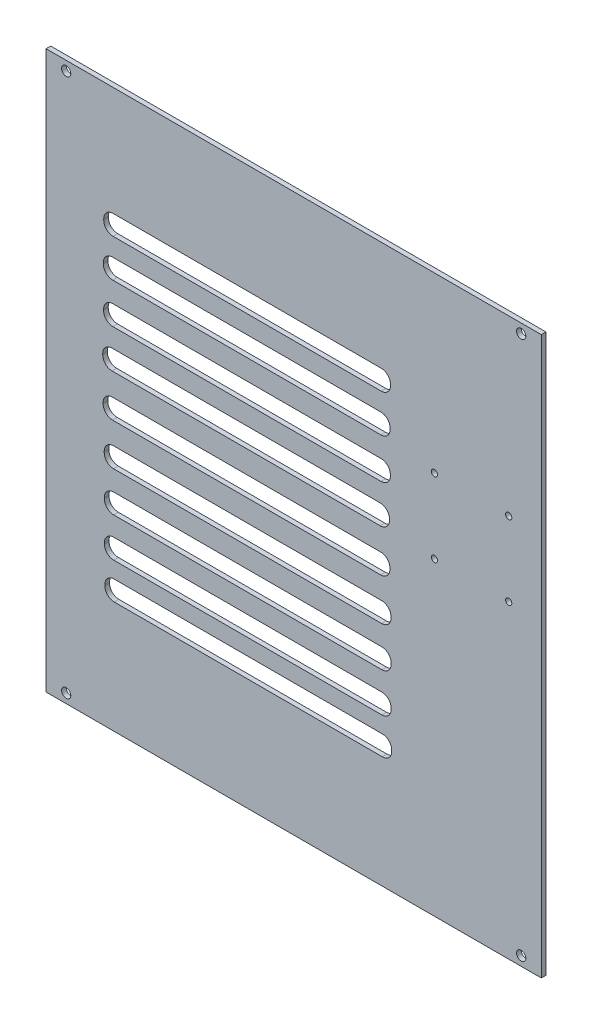
from build123d import *

# Parameters (mm, degrees)
SKETCH_1_W      = 1600
SKETCH_1_H      = 1800
SKETCH_1_R      = 15
SKETCH_1_R_2    = 10
EXTRUDE_1_DEPTH = 3
SCALE_1_SCALE_X = 0.1
SCALE_1_SCALE_Y = 0.1
SCALE_1_SCALE_Z = 0.5


with BuildPart() as part:
    # 草图1 → 凸台-拉伸1 (new body)
    with BuildSketch(Plane.XY):
        with Locations((2560.047324667, 9.612957927)):
            Rectangle(SKETCH_1_W, SKETCH_1_H)
        with Locations((1825.047324667, 879.612957927)):
            Circle(SKETCH_1_R, mode=Mode.SUBTRACT)
        with Locations((1825.047324667, -860.387042073)):
            Circle(SKETCH_1_R, mode=Mode.SUBTRACT)
        with Locations((3295.047324667, -860.387042073)):
            Circle(SKETCH_1_R, mode=Mode.SUBTRACT)
        with Locations((3295.047324667, 879.612957927)):
            Circle(SKETCH_1_R, mode=Mode.SUBTRACT)
        with Locations((3254.707896473, 109.612957927)):
            Circle(SKETCH_1_R_2, mode=Mode.SUBTRACT)
        with Locations((3014.707896473, 109.612957927)):
            Circle(SKETCH_1_R_2, mode=Mode.SUBTRACT)
        with Locations((3254.707896473, 349.612957927)):
            Circle(SKETCH_1_R_2, mode=Mode.SUBTRACT)
        with Locations((3014.707896473, 349.612957927)):
            Circle(SKETCH_1_R_2, mode=Mode.SUBTRACT)
        with BuildLine():
            Line((1975.102126733, 433.943093045), (2841.465354924, 433.943093045))
            ThreePointArc((2841.465354924, 433.943093045), (2862.67855836, 425.15629648), (2871.465354924, 403.943093045))
            Line((2871.465354924, 403.943093045), (2871.465354924, 399.92653687))
            ThreePointArc((2871.465354924, 399.92653687), (2862.67855836, 378.713333435), (2841.465354924, 369.92653687))
            Line((2841.465354924, 369.92653687), (1975.102126733, 369.92653687))
            ThreePointArc((1975.102126733, 369.92653687), (1953.888923298, 378.713333435), (1945.102126733, 399.92653687))
            Line((1945.102126733, 399.92653687), (1945.102126733, 403.943093045))
            ThreePointArc((1945.102126733, 403.943093045), (1953.888923298, 425.15629648), (1975.102126733, 433.943093045))
        make_face(mode=Mode.SUBTRACT)
        with BuildLine():
            Line((1976.452803418, 556.998144036), (2842.816031608, 556.998144036))
            ThreePointArc((2842.816031608, 556.998144036), (2864.029235044, 548.211347472), (2872.816031608, 526.998144036))
            Line((2872.816031608, 526.998144036), (2872.816031608, 522.981587861))
            ThreePointArc((2872.816031608, 522.981587861), (2864.029235044, 501.768384426), (2842.816031608, 492.981587861))
            Line((2842.816031608, 492.981587861), (1976.452803418, 492.981587861))
            ThreePointArc((1976.452803418, 492.981587861), (1955.239599982, 501.768384426), (1946.452803418, 522.981587861))
            Line((1946.452803418, 522.981587861), (1946.452803418, 526.998144036))
            ThreePointArc((1946.452803418, 526.998144036), (1955.239599982, 548.211347472), (1976.452803418, 556.998144036))
        make_face(mode=Mode.SUBTRACT)
        with BuildLine():
            Line((1976.005030783, 304.030402639), (2842.368258974, 304.030402639))
            ThreePointArc((2842.368258974, 304.030402639), (2863.581462409, 295.243606075), (2872.368258974, 274.030402639))
            Line((2872.368258974, 274.030402639), (2872.368258974, 270.013846465))
            ThreePointArc((2872.368258974, 270.013846465), (2863.581462409, 248.800643029), (2842.368258974, 240.013846465))
            Line((2842.368258974, 240.013846465), (1976.005030783, 240.013846465))
            ThreePointArc((1976.005030783, 240.013846465), (1954.791827347, 248.800643029), (1946.005030783, 270.013846465))
            Line((1946.005030783, 270.013846465), (1946.005030783, 274.030402639))
            ThreePointArc((1946.005030783, 274.030402639), (1954.791827347, 295.243606075), (1976.005030783, 304.030402639))
        make_face(mode=Mode.SUBTRACT)
        with BuildLine():
            Line((1973.1456979, 178.597460179), (2839.508926091, 178.597460179))
            ThreePointArc((2839.508926091, 178.597460179), (2860.722129526, 169.810663614), (2869.508926091, 148.597460179))
            Line((2869.508926091, 148.597460179), (2869.508926091, 144.580904004))
            ThreePointArc((2869.508926091, 144.580904004), (2860.722129526, 123.367700569), (2839.508926091, 114.580904004))
            Line((2839.508926091, 114.580904004), (1973.1456979, 114.580904004))
            ThreePointArc((1973.1456979, 114.580904004), (1951.932494464, 123.367700569), (1943.1456979, 144.580904004))
            Line((1943.1456979, 144.580904004), (1943.1456979, 148.597460179))
            ThreePointArc((1943.1456979, 148.597460179), (1951.932494464, 169.810663614), (1973.1456979, 178.597460179))
        make_face(mode=Mode.SUBTRACT)
        with BuildLine():
            Line((1974.549759514, 41.965147856), (2840.912987705, 41.965147856))
            ThreePointArc((2840.912987705, 41.965147856), (2862.12619114, 33.178351291), (2870.912987705, 11.965147856))
            Line((2870.912987705, 11.965147856), (2870.912987705, 7.948591681))
            ThreePointArc((2870.912987705, 7.948591681), (2862.12619114, -13.264611754), (2840.912987705, -22.051408319))
            Line((2840.912987705, -22.051408319), (1974.549759514, -22.051408319))
            ThreePointArc((1974.549759514, -22.051408319), (1953.336556078, -13.264611754), (1944.549759514, 7.948591681))
            Line((1944.549759514, 7.948591681), (1944.549759514, 11.965147856))
            ThreePointArc((1944.549759514, 11.965147856), (1953.336556078, 33.178351291), (1974.549759514, 41.965147856))
        make_face(mode=Mode.SUBTRACT)
        with BuildLine():
            Line((1977.990775053, -92.427290495), (2844.354003244, -92.427290495))
            ThreePointArc((2844.354003244, -92.427290495), (2865.567206679, -101.214087059), (2874.354003244, -122.427290495))
            Line((2874.354003244, -122.427290495), (2874.354003244, -126.443846669))
            ThreePointArc((2874.354003244, -126.443846669), (2865.567206679, -147.657050105), (2844.354003244, -156.443846669))
            Line((2844.354003244, -156.443846669), (1977.990775053, -156.443846669))
            ThreePointArc((1977.990775053, -156.443846669), (1956.777571618, -147.657050105), (1947.990775053, -126.443846669))
            Line((1947.990775053, -126.443846669), (1947.990775053, -122.427290495))
            ThreePointArc((1947.990775053, -122.427290495), (1956.777571618, -101.214087059), (1977.990775053, -92.427290495))
        make_face(mode=Mode.SUBTRACT)
        with BuildLine():
            Line((1978.544420595, -221.49631998), (2844.907648786, -221.49631998))
            ThreePointArc((2844.907648786, -221.49631998), (2866.120852221, -230.283116545), (2874.907648786, -251.49631998))
            Line((2874.907648786, -251.49631998), (2874.907648786, -255.512876155))
            ThreePointArc((2874.907648786, -255.512876155), (2866.120852221, -276.726079591), (2844.907648786, -285.512876155))
            Line((2844.907648786, -285.512876155), (1978.544420595, -285.512876155))
            ThreePointArc((1978.544420595, -285.512876155), (1957.331217159, -276.726079591), (1948.544420595, -255.512876155))
            Line((1948.544420595, -255.512876155), (1948.544420595, -251.49631998))
            ThreePointArc((1948.544420595, -251.49631998), (1957.331217159, -230.283116545), (1978.544420595, -221.49631998))
        make_face(mode=Mode.SUBTRACT)
        with BuildLine():
            Line((1978.579171032, -347.937191407), (2844.942399223, -347.937191407))
            ThreePointArc((2844.942399223, -347.937191407), (2866.155602659, -356.723987971), (2874.942399223, -377.937191407))
            Line((2874.942399223, -377.937191407), (2874.942399223, -381.953747581))
            ThreePointArc((2874.942399223, -381.953747581), (2866.155602659, -403.166951017), (2844.942399223, -411.953747581))
            Line((2844.942399223, -411.953747581), (1978.579171032, -411.953747581))
            ThreePointArc((1978.579171032, -411.953747581), (1957.365967597, -403.166951017), (1948.579171032, -381.953747581))
            Line((1948.579171032, -381.953747581), (1948.579171032, -377.937191407))
            ThreePointArc((1948.579171032, -377.937191407), (1957.365967597, -356.723987971), (1978.579171032, -347.937191407))
        make_face(mode=Mode.SUBTRACT)
        with BuildLine():
            Line((1980.237695533, -464.246369931), (2846.600923724, -464.246369931))
            ThreePointArc((2846.600923724, -464.246369931), (2867.81412716, -473.033166495), (2876.600923724, -494.246369931))
            Line((2876.600923724, -494.246369931), (2876.600923724, -498.262926105))
            ThreePointArc((2876.600923724, -498.262926105), (2867.81412716, -519.476129541), (2846.600923724, -528.262926105))
            Line((2846.600923724, -528.262926105), (1980.237695533, -528.262926105))
            ThreePointArc((1980.237695533, -528.262926105), (1959.024492098, -519.476129541), (1950.237695533, -498.262926105))
            Line((1950.237695533, -498.262926105), (1950.237695533, -494.246369931))
            ThreePointArc((1950.237695533, -494.246369931), (1959.024492098, -473.033166495), (1980.237695533, -464.246369931))
        make_face(mode=Mode.SUBTRACT)
    extrude(amount=EXTRUDE_1_DEPTH)


with BuildPart() as part_1:
    # 缩放比例1: scaled about (2593.405270581, 9.125628159, 1.5)
    add(part.part.scale((SCALE_1_SCALE_X, SCALE_1_SCALE_Y, SCALE_1_SCALE_Z), about=(2593.405270581, 9.125628159, 1.5)))


solid = part_1.part
